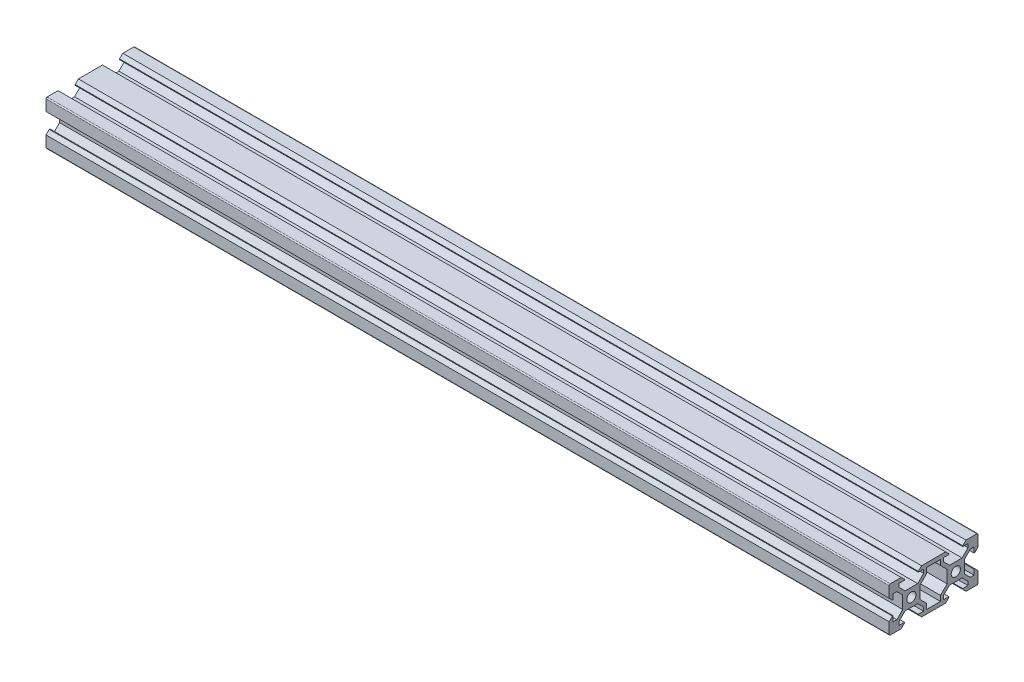
from build123d import *

# Parameters (mm, degrees)
SKETCH2_R           = 2.075
BOSS_EXTRUDE1_DEPTH = 380


with BuildPart() as part:
    # Sketch2 → Boss-Extrude1 (new body)
    with BuildSketch(Plane(origin=(0, 0, 0), x_dir=(0, 0, -1), z_dir=(1, 0, 0))):
        with BuildLine():
            Line((3.125428693, 8.548200862), (3.125428693, 8.203200862))
            Line((3.125428693, 8.203200862), (5.505428693, 8.203200862))
            Line((5.505428693, 8.203200862), (5.505428693, 6.558200862))
            Line((5.505428693, 6.558200862), (2.839571307, 3.903200862))
            Line((2.839571307, 3.903200862), (-2.839571307, 3.903200862))
            Line((-2.839571307, 3.903200862), (-5.505428693, 6.558200862))
            Line((-5.505428693, 6.558200862), (-5.505428693, 8.203200862))
            Line((-5.505428693, 8.203200862), (-3.125428693, 8.203200862))
            Line((-3.125428693, 8.203200862), (-3.125428693, 8.548200862))
            Line((-3.125428693, 8.548200862), (-4.580428693, 10.003200862))
            Line((-4.580428693, 10.003200862), (-9.505428693, 10.003200862))
            ThreePointArc((-9.505428693, 10.003200862), (-9.858982084, 9.856754253), (-10.005428693, 9.503200862))
            Line((-10.005428693, 9.503200862), (-10.005428693, 4.583200862))
            Line((-10.005428693, 4.583200862), (-8.53985696, 3.123200862))
            Line((-8.53985696, 3.123200862), (-8.205428693, 3.123200862))
            Line((-8.205428693, 3.123200862), (-8.205428693, 5.503200862))
            Line((-8.205428693, 5.503200862), (-6.563922349, 5.49537859))
            Line((-6.563922349, 5.49537859), (-3.898064962, 2.84037859))
            Line((-3.898064962, 2.84037859), (-3.898064962, -2.84037859))
            Line((-3.898064962, -2.84037859), (-6.563922349, -5.49537859))
            Line((-6.563922349, -5.49537859), (-8.205428693, -5.503200862))
            Line((-8.205428693, -5.503200862), (-8.205428693, -3.123200862))
            Line((-8.205428693, -3.123200862), (-8.53985696, -3.123200862))
            Line((-8.53985696, -3.123200862), (-10.005428693, -4.583200862))
            Line((-10.005428693, -4.583200862), (-10.005428693, -9.503200862))
            ThreePointArc((-10.005428693, -9.503200862), (-9.858982084, -9.856754253), (-9.505428693, -10.003200862))
            Line((-9.505428693, -10.003200862), (-4.580428693, -10.003200862))
            Line((-4.580428693, -10.003200862), (-3.125428693, -8.548200862))
            Line((-3.125428693, -8.548200862), (-3.125428693, -8.203200862))
            Line((-3.125428693, -8.203200862), (-5.505428693, -8.203200862))
            Line((-5.505428693, -8.203200862), (-5.505428693, -6.558200862))
            Line((-5.505428693, -6.558200862), (-2.839571307, -3.903200862))
            Line((-2.839571307, -3.903200862), (2.839571307, -3.903200862))
            Line((2.839571307, -3.903200862), (5.505428693, -6.558200862))
            Line((5.505428693, -6.558200862), (5.505428693, -8.203200862))
            Line((5.505428693, -8.203200862), (3.125428693, -8.203200862))
            Line((3.125428693, -8.203200862), (3.125428693, -8.548200862))
            Line((3.125428693, -8.548200862), (4.580428693, -10.003200862))
            Line((4.580428693, -10.003200862), (15.430428693, -10.003200862))
            Line((15.430428693, -10.003200862), (16.885428693, -8.548200862))
            Line((16.885428693, -8.548200862), (16.885428693, -8.203200862))
            Line((16.885428693, -8.203200862), (14.505428693, -8.203200862))
            Line((14.505428693, -8.203200862), (14.505428693, -6.558200862))
            Line((14.505428693, -6.558200862), (17.17128608, -3.903200862))
            Line((17.17128608, -3.903200862), (22.850428693, -3.903200862))
            Line((22.850428693, -3.903200862), (25.51628608, -6.558200862))
            Line((25.51628608, -6.558200862), (25.51628608, -8.203200862))
            Line((25.51628608, -8.203200862), (23.13628608, -8.203200862))
            Line((23.13628608, -8.203200862), (23.13628608, -8.548200862))
            Line((23.13628608, -8.548200862), (24.59128608, -10.003200862))
            Line((24.59128608, -10.003200862), (29.51628608, -10.003200862))
            ThreePointArc((29.51628608, -10.003200862), (29.869839471, -9.856754253), (30.01628608, -9.503200862))
            Line((30.01628608, -9.503200862), (30.01628608, -4.583200862))
            Line((30.01628608, -4.583200862), (28.550714346, -3.123200862))
            Line((28.550714346, -3.123200862), (28.21628608, -3.123200862))
            Line((28.21628608, -3.123200862), (28.21628608, -5.503200862))
            Line((28.21628608, -5.503200862), (26.574779736, -5.49537859))
            Line((26.574779736, -5.49537859), (23.908922349, -2.84037859))
            Line((23.908922349, -2.84037859), (23.908922349, 2.84037859))
            Line((23.908922349, 2.84037859), (26.574779736, 5.49537859))
            Line((26.574779736, 5.49537859), (28.21628608, 5.503200862))
            Line((28.21628608, 5.503200862), (28.21628608, 3.123200862))
            Line((28.21628608, 3.123200862), (28.550714346, 3.123200862))
            Line((28.550714346, 3.123200862), (30.01628608, 4.583200862))
            Line((30.01628608, 4.583200862), (30.01628608, 9.503200862))
            ThreePointArc((30.01628608, 9.503200862), (29.869839471, 9.856754253), (29.51628608, 10.003200862))
            Line((29.51628608, 10.003200862), (24.59128608, 10.003200862))
            Line((24.59128608, 10.003200862), (23.13628608, 8.548200862))
            Line((23.13628608, 8.548200862), (23.13628608, 8.203200862))
            Line((23.13628608, 8.203200862), (25.51628608, 8.203200862))
            Line((25.51628608, 8.203200862), (25.51628608, 6.558200862))
            Line((25.51628608, 6.558200862), (22.850428693, 3.903200862))
            Line((22.850428693, 3.903200862), (17.17128608, 3.903200862))
            Line((17.17128608, 3.903200862), (14.505428693, 6.558200862))
            Line((14.505428693, 6.558200862), (14.505428693, 8.203200862))
            Line((14.505428693, 8.203200862), (16.885428693, 8.203200862))
            Line((16.885428693, 8.203200862), (16.885428693, 8.548200862))
            Line((16.885428693, 8.548200862), (15.430428693, 10.003200862))
            Line((15.430428693, 10.003200862), (4.580428693, 10.003200862))
            Line((4.580428693, 10.003200862), (3.125428693, 8.548200862))
        make_face()
        with Locations((0.003681866, 0)):
            Circle(SKETCH2_R, mode=Mode.SUBTRACT)
        with Locations((20.007175521, 0)):
            Circle(SKETCH2_R, mode=Mode.SUBTRACT)
        Polygon((3.898064962, 2.84037859), (3.898064962, -2.84037859), (6.90134296, -5.83142497), (6.90134296, -8.203200862), (13.109514426, -8.203200862), (13.109514426, -5.83142497), (16.112792425, -2.84037859), (16.112792425, 2.84037859), (13.109514426, 5.83142497), (13.109514426, 8.203200862), (6.90134296, 8.203200862), (6.90134296, 5.83142497), align=None, mode=Mode.SUBTRACT)
    extrude(amount=BOSS_EXTRUDE1_DEPTH)


solid = part.part
